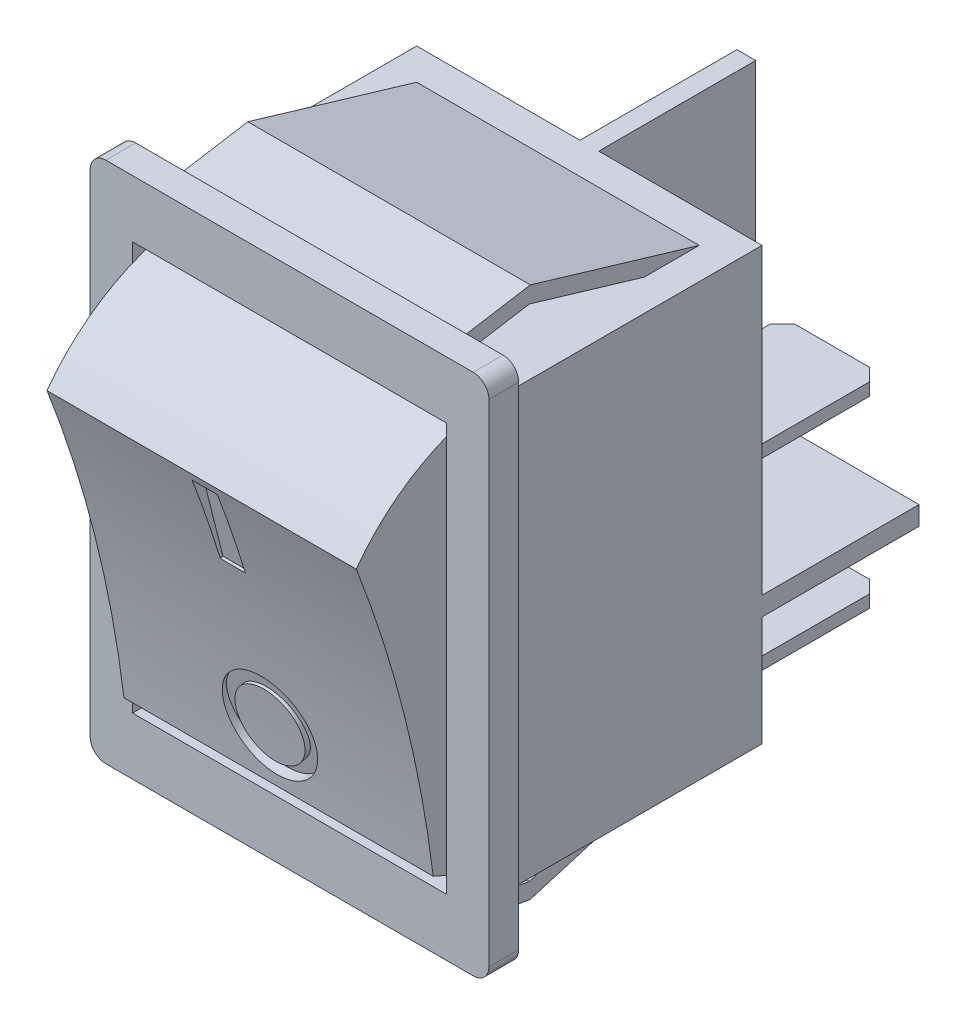
from build123d import *

# Parameters (mm, degrees)
SKETCH1_W           = 20
SKETCH1_H           = 26
EXTRUDE1_DEPTH      = 1.9
SKETCH2_W           = 22
SKETCH2_H           = 27.5
EXTRUDE2_DEPTH      = 17.2
SKETCH3_W           = 19.7
SKETCH3_H           = 25
EXTRUDE3_DEPTH      = 7.6
CUT_EXTRUDE1_DEPTH  = 19.7
SKETCH5_R           = 3
SKETCH5_R_2         = 2.2
SKETCH5_W           = 1.6
SKETCH5_H           = 5.5
CUT_EXTRUDE2_DEPTH  = 0.7
SKETCH6_R           = 80.623139619
CUT_EXTRUDE3_DEPTH  = 23.55
SKETCH7_W           = 6.35
SKETCH7_H           = 0.8
EXTRUDE4_DEPTH      = 10
CHAMFER1_SIZE       = 0.8
EXTRUDE5_DEPTH      = 9
EXTRUDE5_DEPTH_BACK = 9


with BuildPart() as part:
    # Sketch1 → Extrude1 (new body)
    with BuildSketch(Plane.XY):
        with BuildLine():
            Line((-11.7, -16.65), (11.7, -16.65))
            ThreePointArc((11.7, -16.65), (12.407106781, -16.357106781), (12.7, -15.65))
            Line((12.7, -15.65), (12.7, 15.65))
            ThreePointArc((12.7, 15.65), (12.407106781, 16.357106781), (11.7, 16.65))
            Line((11.7, 16.65), (-11.7, 16.65))
            ThreePointArc((-11.7, 16.65), (-12.407106781, 16.357106781), (-12.7, 15.65))
            Line((-12.7, 15.65), (-12.7, -15.65))
            ThreePointArc((-12.7, -15.65), (-12.407106781, -16.357106781), (-11.7, -16.65))
        make_face()
        Rectangle(SKETCH1_W, SKETCH1_H, mode=Mode.SUBTRACT)
    extrude(amount=EXTRUDE1_DEPTH)

    # Sketch2 → Extrude2 (add)
    with BuildSketch(Plane(origin=(0, 0, 0), x_dir=(-1, 0, 0), z_dir=(0, 0, -1))):
        Rectangle(SKETCH2_W, SKETCH2_H)
    extrude(amount=EXTRUDE2_DEPTH)

    # Sketch3 → Extrude3 (add)
    with BuildSketch(Plane.XY):
        Rectangle(SKETCH3_W, SKETCH3_H)
    extrude(amount=EXTRUDE3_DEPTH)

    # Sketch4 → Cut-Extrude1 (cut)
    with BuildSketch(Plane.ZY.offset(9.85)):
        with BuildLine():
            Line((0, -12.649110641), (10.2, -12.649110641))
            Line((10.2, -12.649110641), (10.2, 12.649110641))
            Line((10.2, 12.649110641), (0, 12.649110641))
            ThreePointArc((0, 12.649110641), (4.195359715, 10.827132519), (7.5, 7.664854858))
            Line((7.5, 7.664854858), (2.595963169, -11.733933535))
            ThreePointArc((2.595963169, -11.733933535), (1.322271739, -12.260422791), (0, -12.649110641))
        make_face()
    extrude(amount=-CUT_EXTRUDE1_DEPTH, mode=Mode.SUBTRACT)

    # Sketch5 → Cut-Extrude2 (cut)
    with BuildSketch(Plane(origin=(0, -1.321692682, 5.228190069), x_dir=(1, 0, 0), z_dir=(0, -0.245090789, 0.969500132))):
        with Locations((0, -7)):
            Circle(SKETCH5_R)
        with Locations((0, -7)):
            Circle(SKETCH5_R_2, mode=Mode.SUBTRACT)
        with Locations((0, 5.971443692)):
            Rectangle(SKETCH5_W, SKETCH5_H)
    extrude(amount=-CUT_EXTRUDE2_DEPTH, mode=Mode.SUBTRACT)

    # Sketch6 → Cut-Extrude3 (cut, through all)
    with BuildSketch(Plane.ZY.offset(9.85)):
        with Locations((82.607992112, -21.641802457)):
            Circle(SKETCH6_R)
    extrude(amount=-CUT_EXTRUDE3_DEPTH, mode=Mode.SUBTRACT)

    # Sketch7 → Extrude4 (add)
    with BuildSketch(Plane(origin=(0, 0, -17.2), x_dir=(-1, 0, 0), z_dir=(0, 0, -1))):
        Polygon((-0.6, -13.75), (0.6, -13.75), (0.6, -6.75), (11, -6.75), (11, -5.55), (0.6, -5.55), (0.6, 13.75), (-0.6, 13.75), (-0.6, -5.55), (-11, -5.55), (-11, -6.75), (-0.6, -6.75), align=None)
        with Locations((-5.475, 0.05)):
            Rectangle(SKETCH7_W, SKETCH7_H)
        with Locations((5.475, 0.05)):
            Rectangle(SKETCH7_W, SKETCH7_H)
        with Locations((-5.475, -11.65)):
            Rectangle(SKETCH7_W, SKETCH7_H)
        with Locations((5.475, -11.65)):
            Rectangle(SKETCH7_W, SKETCH7_H)
    extrude(amount=EXTRUDE4_DEPTH)

    # Chamfer1
    chamfer1_edges = [part.edges().sort_by_distance(p)[0] for p in [
        (8.65, 0.05, -27.2),
        (2.3, 0.05, -27.2),
        (-2.3, 0.05, -27.2),
        (-8.65, 0.05, -27.2),
        (8.65, -11.65, -27.2),
        (2.3, -11.65, -27.2),
        (-2.3, -11.65, -27.2),
        (-8.65, -11.65, -27.2),
    ]]
    chamfer(chamfer1_edges, length=CHAMFER1_SIZE)

    # Sketch8 → Extrude5 (add, two sides)
    with BuildSketch(Plane(origin=(0, 0, 0), x_dir=(0, 0, -1), z_dir=(1, 0, 0))) as extrude5_sk:
        Polygon((15.2, 13.75), (4.442640687, 16.95), (0.2, 16.25), (0.362790698, 15.263339375), (4.378231172, 15.925853253), (14.914876963, 12.791509075), align=None)
        Polygon((15.2, -13.75), (4.442640687, -16.95), (0.2, -16.25), (0.362790698, -15.263339375), (4.378231172, -15.925853253), (14.914876963, -12.791509075), align=None)
    extrude(amount=EXTRUDE5_DEPTH)
    extrude(extrude5_sk.sketch, amount=-EXTRUDE5_DEPTH_BACK)


solid = part.part
